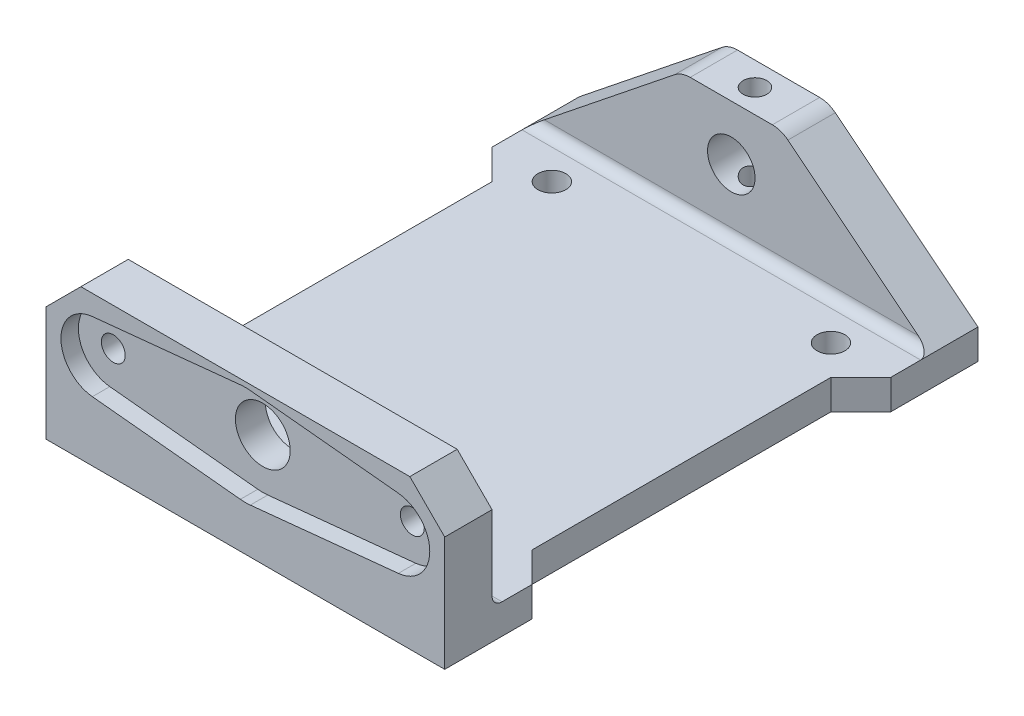
from build123d import *

# Parameters (mm, degrees)
SKETCH1_W           = 40
SKETCH1_H           = 44
SKETCH1_R           = 1.4
BOSS_EXTRUDE1_DEPTH = 3
SKETCH2_W           = 40
SKETCH2_H           = 15
BOSS_EXTRUDE2_DEPTH = 4.75
SKETCH3_W           = 40
SKETCH3_H           = 15
BOSS_EXTRUDE3_DEPTH = 4.75
CUT_EXTRUDE1_DEPTH  = 1.75
CUT_EXTRUDE2_REACH  = 53.75
SKETCH5_R           = 1.2
SKETCH5_R_2         = 2.75
CUT_EXTRUDE3_REACH  = 55.5
SKETCH6_R           = 2.38125
SKETCH7_R           = 1.190625
CUT_EXTRUDE4_DEPTH  = 16
CUT_EXTRUDE5_REACH  = 5
CUT_EXTRUDE6_REACH  = 55.5
FILLET1_R           = 1
CHAMFER1_SIZE       = 3.5
FILLET2_R           = 2.5


with BuildPart() as part:
    # Sketch1 → Boss-Extrude1 (new body)
    with BuildSketch(Plane(origin=(0, 0, 0), x_dir=(1, 0, 0), z_dir=(0, 1, 0))):
        Rectangle(SKETCH1_W, SKETCH1_H)
        with Locations((-14, 18)):
            Circle(SKETCH1_R, mode=Mode.SUBTRACT)
        with Locations((14, 18)):
            Circle(SKETCH1_R, mode=Mode.SUBTRACT)
        with Locations((-14, -18)):
            Circle(SKETCH1_R, mode=Mode.SUBTRACT)
        with Locations((14, -18)):
            Circle(SKETCH1_R, mode=Mode.SUBTRACT)
    extrude(amount=BOSS_EXTRUDE1_DEPTH)

    # Sketch2 → Boss-Extrude2 (add)
    with BuildSketch(Plane.XY.offset(22)):
        with Locations((0, 7.5)):
            Rectangle(SKETCH2_W, SKETCH2_H)
    extrude(amount=BOSS_EXTRUDE2_DEPTH)

    # Sketch3 → Boss-Extrude3 (add)
    with BuildSketch(Plane(origin=(0, 0, -22), x_dir=(-1, 0, 0), z_dir=(0, 0, -1))):
        with Locations((0, 7.5)):
            Rectangle(SKETCH3_W, SKETCH3_H)
    extrude(amount=BOSS_EXTRUDE3_DEPTH)

    # Sketch4 → Cut-Extrude1 (cut)
    with BuildSketch(Plane.XY.offset(26.75)):
        with BuildLine():
            Line((15.35, 12.98245603), (0.5, 14.474937186))
            ThreePointArc((0.5, 14.474937186), (0, 14.5), (-0.5, 14.474937186))
            Line((-0.5, 14.474937186), (-15.35, 12.98245603))
            ThreePointArc((-15.35, 12.98245603), (-18.5, 9.5), (-15.35, 6.01754397))
            Line((-15.35, 6.01754397), (-0.5, 4.525062814))
            ThreePointArc((-0.5, 4.525062814), (0, 4.5), (0.5, 4.525062814))
            Line((0.5, 4.525062814), (15.35, 6.01754397))
            ThreePointArc((15.35, 6.01754397), (18.5, 9.5), (15.35, 12.98245603))
        make_face()
    extrude(amount=-CUT_EXTRUDE1_DEPTH, mode=Mode.SUBTRACT)

    # Sketch5 → Cut-Extrude2 (cut, up to next)
    with BuildSketch(Plane.XY.offset(25), mode=Mode.PRIVATE) as cut_extrude2_sk1:
        with Locations((-15, 9.5)):
            Circle(SKETCH5_R)
    cut_extrude2_tool1 = extrude(cut_extrude2_sk1.sketch, amount=-CUT_EXTRUDE2_REACH, mode=Mode.PRIVATE) & part.part
    add(cut_extrude2_tool1.solids().sort_by_distance((-15, 9.5, 25))[0], mode=Mode.SUBTRACT)
    # Sketch5 → Cut-Extrude2 (cut, up to next)
    with BuildSketch(Plane.XY.offset(25), mode=Mode.PRIVATE) as cut_extrude2_sk2:
        with Locations((15, 9.5)):
            Circle(SKETCH5_R)
    cut_extrude2_tool2 = extrude(cut_extrude2_sk2.sketch, amount=-CUT_EXTRUDE2_REACH, mode=Mode.PRIVATE) & part.part
    add(cut_extrude2_tool2.solids().sort_by_distance((15, 9.5, 25))[0], mode=Mode.SUBTRACT)
    # Sketch5 → Cut-Extrude2 (cut, up to next)
    with BuildSketch(Plane.XY.offset(25), mode=Mode.PRIVATE) as cut_extrude2_sk3:
        with Locations((0, 9.5)):
            Circle(SKETCH5_R_2)
    cut_extrude2_tool3 = extrude(cut_extrude2_sk3.sketch, amount=-CUT_EXTRUDE2_REACH, mode=Mode.PRIVATE) & part.part
    add(cut_extrude2_tool3.solids().sort_by_distance((0, 9.5, 25))[0], mode=Mode.SUBTRACT)

    # Sketch6 → Cut-Extrude3 (cut, up to next)
    with BuildSketch(Plane(origin=(0, 0, -26.75), x_dir=(-1, 0, 0), z_dir=(0, 0, -1)), mode=Mode.PRIVATE) as cut_extrude3_sk1:
        with Locations((0, 9.5)):
            Circle(SKETCH6_R)
    cut_extrude3_tool1 = extrude(cut_extrude3_sk1.sketch, amount=-CUT_EXTRUDE3_REACH, mode=Mode.PRIVATE) & part.part
    add(cut_extrude3_tool1.solids().sort_by_distance((0, 9.5, -26.75))[0], mode=Mode.SUBTRACT)

    # Sketch7 → Cut-Extrude4 (cut, through all)
    with BuildSketch(Plane(origin=(0, 15, 0), x_dir=(1, 0, 0), z_dir=(0, 1, 0))):
        with Locations((0, 24.375)):
            Circle(SKETCH7_R)
    extrude(amount=-CUT_EXTRUDE4_DEPTH, mode=Mode.SUBTRACT)

    # Sketch8 → Cut-Extrude5 (cut, up to next)
    with BuildSketch(Plane(origin=(0, 3, 0), x_dir=(1, 0, 0), z_dir=(0, 1, 0)), mode=Mode.PRIVATE) as cut_extrude5_sk1:
        Polygon((-20, 18), (-17, 15), (-17, -15), (-20, -18), align=None)
    cut_extrude5_tool1 = extrude(cut_extrude5_sk1.sketch, amount=-CUT_EXTRUDE5_REACH, mode=Mode.PRIVATE) & part.part
    add(cut_extrude5_tool1.solids().sort_by_distance((-18.545455, 3, 0))[0], mode=Mode.SUBTRACT)
    # Sketch8 → Cut-Extrude5 (cut, up to next)
    with BuildSketch(Plane(origin=(0, 3, 0), x_dir=(1, 0, 0), z_dir=(0, 1, 0)), mode=Mode.PRIVATE) as cut_extrude5_sk2:
        Polygon((17, -15), (20, -18), (20, 18), (17, 15), align=None)
    cut_extrude5_tool2 = extrude(cut_extrude5_sk2.sketch, amount=-CUT_EXTRUDE5_REACH, mode=Mode.PRIVATE) & part.part
    add(cut_extrude5_tool2.solids().sort_by_distance((18.545455, 3, 0))[0], mode=Mode.SUBTRACT)

    # Sketch9 → Cut-Extrude6 (cut, up to next)
    with BuildSketch(Plane(origin=(0, 0, -26.75), x_dir=(-1, 0, 0), z_dir=(0, 0, -1)), mode=Mode.PRIVATE) as cut_extrude6_sk1:
        Polygon((-20, 15), (-4.995024308, 15), (-20, 3), align=None)
    cut_extrude6_tool1 = extrude(cut_extrude6_sk1.sketch, amount=-CUT_EXTRUDE6_REACH, mode=Mode.PRIVATE) & part.part
    add(cut_extrude6_tool1.solids().sort_by_distance((14.998341, 11, -26.75))[0], mode=Mode.SUBTRACT)
    # Sketch9 → Cut-Extrude6 (cut, up to next)
    with BuildSketch(Plane(origin=(0, 0, -26.75), x_dir=(-1, 0, 0), z_dir=(0, 0, -1)), mode=Mode.PRIVATE) as cut_extrude6_sk2:
        Polygon((20, 15), (5, 15), (20, 3), align=None)
    cut_extrude6_tool2 = extrude(cut_extrude6_sk2.sketch, amount=-CUT_EXTRUDE6_REACH, mode=Mode.PRIVATE) & part.part
    add(cut_extrude6_tool2.solids().sort_by_distance((-15, 11, -26.75))[0], mode=Mode.SUBTRACT)

    # Fillet1
    fillet1_edges = [part.edges().sort_by_distance(p)[0] for p in [
        (0, 3, -22),
        (0, 3, 22),
    ]]
    fillet(fillet1_edges, radius=FILLET1_R)

    # Chamfer1
    chamfer1_edges = [part.edges().sort_by_distance(p)[0] for p in [
        (-20, 15, 24.375),
        (20, 15, 24.375),
    ]]
    chamfer(chamfer1_edges, length=CHAMFER1_SIZE)

    # Fillet2
    fillet2_edges = [part.edges().sort_by_distance(p)[0] for p in [
        (4.995024308, 15, -24.375),
        (-5, 15, -24.375),
    ]]
    fillet(fillet2_edges, radius=FILLET2_R)


solid = part.part
